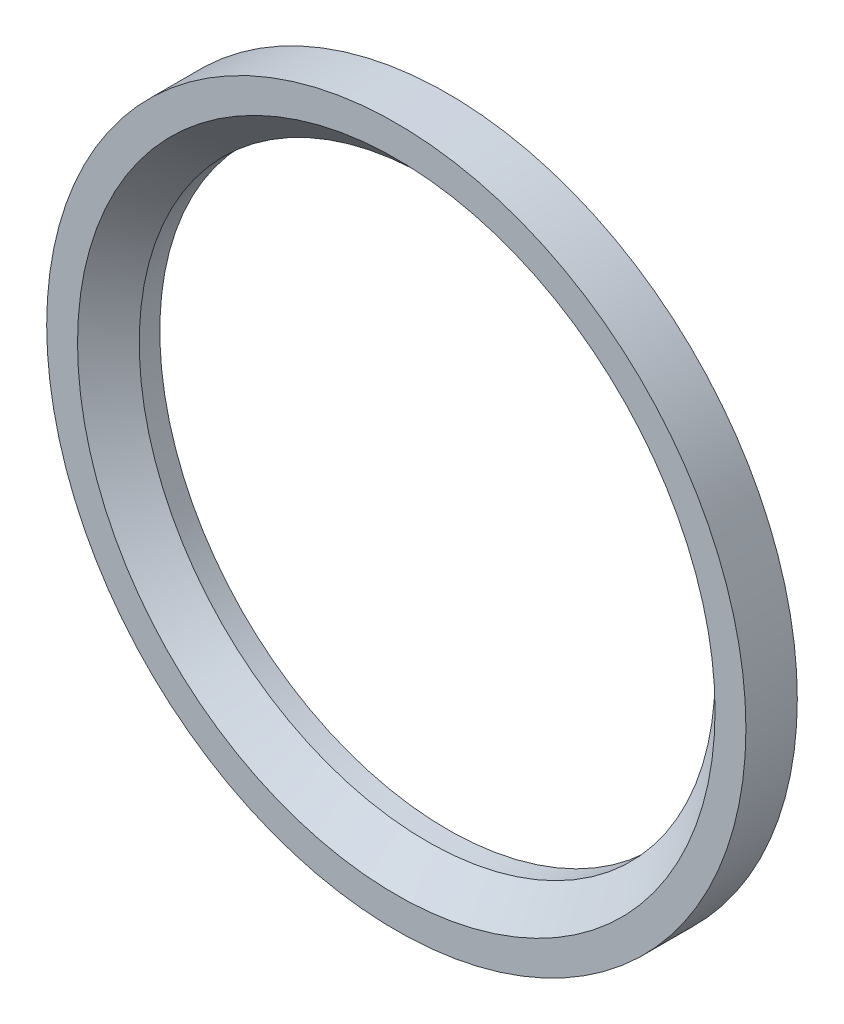
from build123d import *

# Parameters (mm, degrees)
SKETCH1_R           = 17
SKETCH1_R_2         = 14
BOSS_EXTRUDE1_DEPTH = 2.5
CHAMFER1_SIZE       = 1.5


with BuildPart() as part:
    # Sketch1 → Boss-Extrude1 (new body)
    with BuildSketch(Plane.XY):
        Circle(SKETCH1_R)
        Circle(SKETCH1_R_2, mode=Mode.SUBTRACT)
    extrude(amount=BOSS_EXTRUDE1_DEPTH)

    # Chamfer1
    chamfer1_edges = [part.edges().sort_by_distance(p)[0] for p in [
        (-14, 0, 2.5),
    ]]
    chamfer(chamfer1_edges, length=CHAMFER1_SIZE)


solid = part.part
